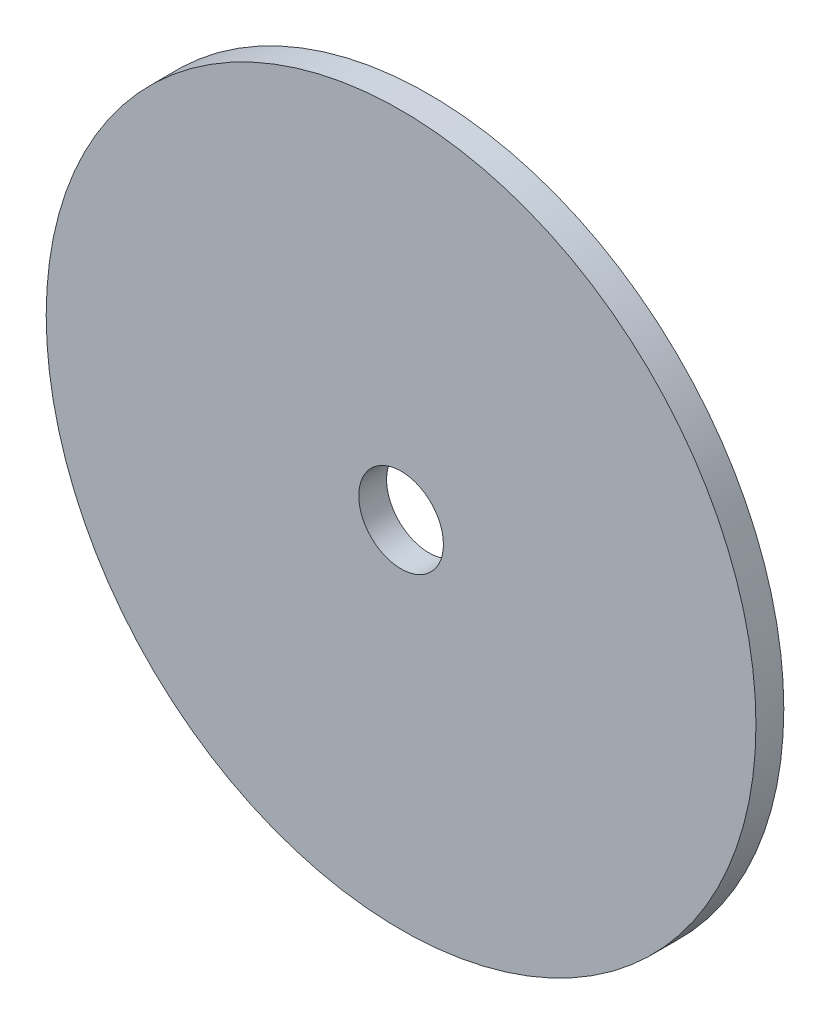
from build123d import *

# Parameters (mm, degrees)
SKETCH1_R           = 63.70040654
SKETCH1_R_2         = 7.6
BOSS_EXTRUDE1_DEPTH = 5


with BuildPart() as part:
    # Sketch1 → Boss-Extrude1 (new body)
    with BuildSketch(Plane.XY):
        Circle(SKETCH1_R)
        Circle(SKETCH1_R_2, mode=Mode.SUBTRACT)
    extrude(amount=BOSS_EXTRUDE1_DEPTH)


solid = part.part
